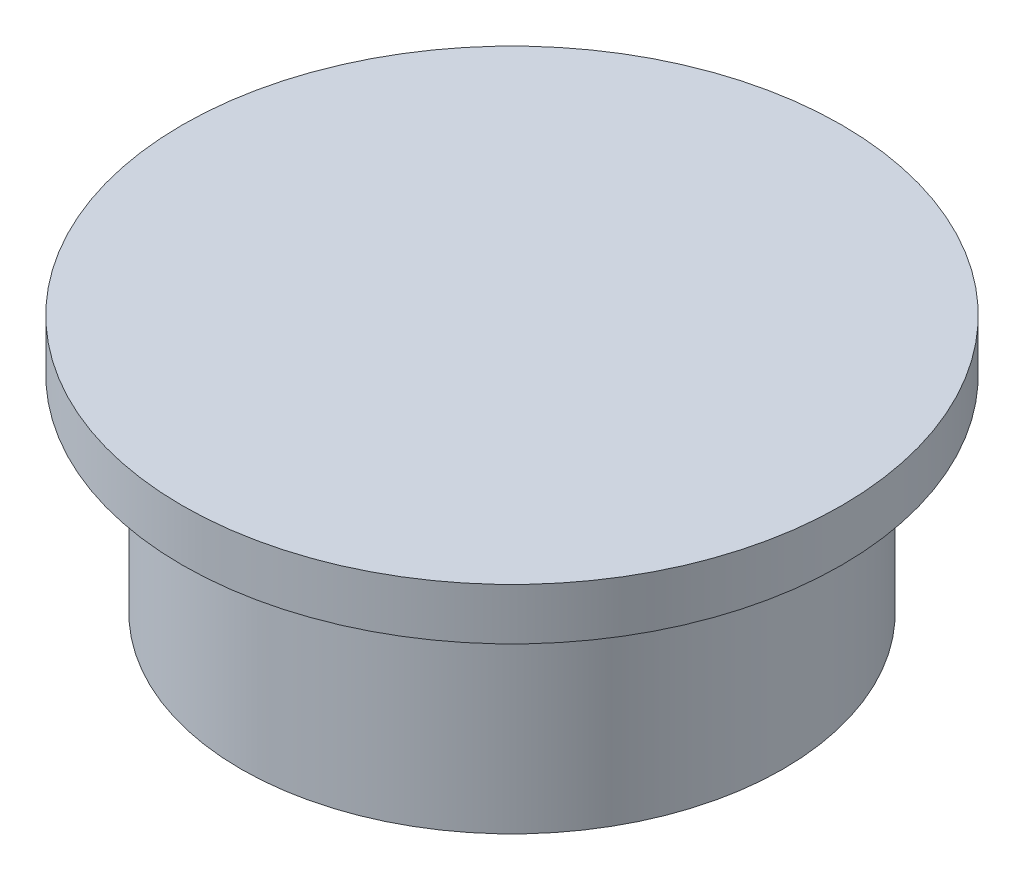
from build123d import *

# Parameters (mm, degrees)
SKETCH1_R           = 12.65
SKETCH1_R_2         = 10.65
BOSS_EXTRUDE1_DEPTH = 15
SKETCH2_R           = 16
BOSS_EXTRUDE2_DEPTH = 2
CUT_EXTRUDE2_DEPTH  = 3.3
SKETCH5_R           = 16
BOSS_EXTRUDE4_DEPTH = 0.5
SKETCH7_R           = 13.15
SKETCH7_R_2         = 12.65
BOSS_EXTRUDE5_DEPTH = 15
BOSS_EXTRUDE6_DEPTH = 2
SKETCH10_R          = 13.15
CUT_EXTRUDE3_DEPTH  = 5
SKETCH11_R          = 10.65
CUT_EXTRUDE4_DEPTH  = 2


with BuildPart() as part:
    # Sketch1 → Boss-Extrude1 (new body)
    with BuildSketch(Plane(origin=(0, 0, 0), x_dir=(1, 0, 0), z_dir=(0, 1, 0))):
        with Locations(Location((0, 0, 0), (0, 0, 270))):
            Circle(SKETCH1_R)
        with Locations(Location((0, 0, 0), (0, 0, 270))):
            Circle(SKETCH1_R_2, mode=Mode.SUBTRACT)
    extrude(amount=BOSS_EXTRUDE1_DEPTH)

    # Sketch2 → Boss-Extrude2 (add)
    with BuildSketch(Plane(origin=(0, 15, 0), x_dir=(1, 0, 0), z_dir=(0, 1, 0))):
        with Locations(Location((0, 0, 0), (0, 0, 270))):
            Circle(SKETCH2_R)
    extrude(amount=BOSS_EXTRUDE2_DEPTH)

    # Sketch4 → Cut-Extrude2 (cut)
    with BuildSketch(Plane(origin=(0, 17, 0), x_dir=(1, 0, 0), z_dir=(0, 1, 0))):
        with BuildLine():
            ThreePointArc((-7.706902754, 1.808391197), (-7.603132783, 1.898306548), (-7.527733553, 2.013058165))
            add(Edge.make_bspline(
                [(-5.973562898, 3.427644412), (-6.705514393, 3.181828062), (-7.188037686, 2.727956598), (-7.527733553, 2.013058165)],
                knots=[0.175947617, 0.175947617, 0.175947617, 0.175947617, 0.967261409, 0.967261409, 0.967261409, 0.967261409], degree=3))
            ThreePointArc((-5.973562898, 3.427644412), (-5.5249107, 3.522844059), (-5.066368092, 3.513333887))
            add(Edge.make_bspline(
                [(0.252246957, 2.546498923), (-0.967265157, 2.585544634), (-2.911735898, 3.219251878), (-5.066368092, 3.513333887)],
                knots=[0, 0, 0, 0, 0.944652434, 0.944652434, 0.944652434, 0.944652434], degree=3))
            add(Edge.make_bspline(
                [(2.984843767, 2.898010668), (1.699544821, 2.557369315), (0.252246957, 2.546498923)],
                knots=[0, 0, 0, 1, 1, 1], degree=2))
            add(Edge.make_bspline(
                [(1.446576088, 1.819612756), (1.692233604, 2.009446504), (2.255675441, 2.356061237), (2.984843767, 2.898010668)],
                knots=[0.144955644, 0.144955644, 0.144955644, 0.144955644, 1, 1, 1, 1], degree=3))
            ThreePointArc((1.446576088, 1.819612756), (1.407722351, 1.740462389), (1.446612546, 1.661329929))
            add(Edge.make_bspline(
                [(10.133171434, -3.748192499), (7.984235622, -2.549090336), (4.381903984, -0.604779848), (1.446612546, 1.661329929)],
                knots=[0.010904337, 0.010904337, 0.010904337, 0.010904337, 1, 1, 1, 1], degree=3))
            Line((10.133171434, -3.748192499), (-3.273421479, -3.865089106))
            add(Edge.make_bspline(
                [(-7.527733553, 0.078549357), (-6.021351328, 0.034537537), (-5.034172952, -1.161131544), (-3.273421479, -3.865089106)],
                knots=[0, 0, 0, 0, 1, 1, 1, 1], degree=3))
            add(Edge.make_bspline(
                [(-9.001359598, -0.096644929), (-8.609511327, -0.010984191), (-8.147442934, 0.043060836), (-7.527733553, 0.078549357)],
                knots=[0.366671919, 0.366671919, 0.366671919, 0.366671919, 1, 1, 1, 1], degree=3))
            ThreePointArc((-9.001359598, -0.096644929), (-9.440291534, -0.378150341), (-9.589622684, -0.877756935))
            Line((-9.589622684, -0.877756935), (-9.555879634, -1.399381307))
            Line((-9.555879634, -1.399381307), (-10.239201334, 0.078549357))
            ThreePointArc((-10.239201334, 0.078549357), (-10.259690649, 0.446534823), (-10.022461777, 0.728590805))
            add(Edge.make_bspline(
                [(-7.706902754, 1.808391197), (-8.132820465, 1.531622413), (-9.295077766, 1.120365549), (-10.022461777, 0.728590805)],
                knots=[0.10934646, 0.10934646, 0.10934646, 0.10934646, 0.840811763, 0.840811763, 0.840811763, 0.840811763], degree=3))
        make_face()
        with BuildLine():
            add(Edge.make_bspline(
                [(-6.583224352, 1.672229032), (-6.265045802, 1.812995825), (-5.554174981, 1.756337096)],
                knots=[0, 0, 0, 1, 1, 1], degree=2))
            ThreePointArc((-5.554174981, 1.756337096), (-5.456989048, 1.782455761), (-5.398182511, 1.864120205))
            add(Edge.make_bspline(
                [(-5.398182511, 1.864120205), (-5.299215588, 2.205704199), (-5.024689184, 2.452345347)],
                knots=[0, 0, 0, 1, 1, 1], degree=2))
            add(Edge.make_bspline(
                [(-5.024689184, 2.452345347), (-5.951430889, 2.228368239), (-6.944366579, 2.126753853)],
                knots=[0, 0, 0, 1, 1, 1], degree=2))
            add(Edge.make_bspline(
                [(-6.944366579, 2.126753853), (-6.855792408, 2.003769494), (-6.788085292, 1.768000929)],
                knots=[0, 0, 0, 1, 1, 1], degree=2))
            ThreePointArc((-6.788085292, 1.768000929), (-6.707437973, 1.673519717), (-6.583224352, 1.672229032))
        make_face(mode=Mode.SUBTRACT)
        with BuildLine():
            ThreePointArc((-6.788085292, 1.768000929), (-6.707437973, 1.673519717), (-6.583224352, 1.672229032))
            add(Edge.make_bspline(
                [(-6.583224352, 1.672229032), (-6.265045802, 1.812995825), (-5.554174981, 1.756337096)],
                knots=[0, 0, 0, 1, 1, 1], degree=2))
            ThreePointArc((-5.554174981, 1.756337096), (-5.456989048, 1.782455761), (-5.398182511, 1.864120205))
            add(Edge.make_bspline(
                [(-5.398182511, 1.864120205), (-5.299215588, 2.205704199), (-5.024689184, 2.452345347)],
                knots=[0, 0, 0, 1, 1, 1], degree=2))
            add(Edge.make_bspline(
                [(-5.024689184, 2.452345347), (-5.951430889, 2.228368239), (-6.944366579, 2.126753853)],
                knots=[0, 0, 0, 1, 1, 1], degree=2))
            add(Edge.make_bspline(
                [(-6.944366579, 2.126753853), (-6.855792408, 2.003769494), (-6.788085292, 1.768000929)],
                knots=[0, 0, 0, 1, 1, 1], degree=2))
        make_face()
    extrude(amount=-CUT_EXTRUDE2_DEPTH, mode=Mode.SUBTRACT)

    # Sketch5 → Boss-Extrude4 (add)
    with BuildSketch(Plane(origin=(0, 17, 0), x_dir=(1, 0, 0), z_dir=(0, 1, 0))):
        with Locations(Location((0, 0, 0), (0, 0, 270))):
            Circle(SKETCH5_R)
    extrude(amount=BOSS_EXTRUDE4_DEPTH)

    # Sketch7 → Boss-Extrude5 (add)
    with BuildSketch(Plane.XZ):
        with Locations(Location((0, 0, 0), (0, 0, 270))):
            Circle(SKETCH7_R)
        Circle(SKETCH7_R_2, mode=Mode.SUBTRACT)
    extrude(amount=-BOSS_EXTRUDE5_DEPTH)

    # Sketch8 → Boss-Extrude6 (add)
    with BuildSketch(Plane.XZ.offset(-15)):
        with BuildLine():
            add(Edge.make_bspline(
                [(9.996866834, 3.672213707), (10.042920822, 3.697861429), (10.088362097, 3.723188972), (10.133171434, 3.748192499)],
                knots=[0.979375502, 0.979375502, 0.979375502, 0.979375502, 1, 1, 1, 1], degree=3))
            Line((10.133171434, 3.748192499), (9.9680871, 3.749631925))
            Line((9.9680871, 3.749631925), (-3.273421479, 3.865089106))
            add(Edge.make_bspline(
                [(-3.273421479, 3.865089106), (-5.034172952, 1.161131544), (-6.021351328, -0.034537537), (-7.527733553, -0.078549357)],
                knots=[0, 0, 0, 0, 1, 1, 1, 1], degree=3))
            add(Edge.make_bspline(
                [(-7.527733553, -0.078549357), (-8.147442934, -0.043060836), (-8.609511327, 0.010984191), (-9.001359598, 0.096644929)],
                knots=[0.366671919, 0.366671919, 0.366671919, 0.366671919, 1, 1, 1, 1], degree=3))
            ThreePointArc((-9.001359598, 0.096644929), (-9.440291534, 0.378150341), (-9.589622684, 0.877756935))
            Line((-9.589622684, 0.877756935), (-9.555879634, 1.399381307))
            Line((-9.555879634, 1.399381307), (-10.239201334, -0.078549357))
            ThreePointArc((-10.239201334, -0.078549357), (-10.259690649, -0.446534823), (-10.022461777, -0.728590805))
            add(Edge.make_bspline(
                [(-10.022461777, -0.728590805), (-9.295077766, -1.120365549), (-8.132820465, -1.531622413), (-7.706902754, -1.808391197)],
                knots=[0.10934646, 0.10934646, 0.10934646, 0.10934646, 0.840811763, 0.840811763, 0.840811763, 0.840811763], degree=3))
            ThreePointArc((-7.706902754, -1.808391197), (-7.603132783, -1.898306548), (-7.527733553, -2.013058165))
            add(Edge.make_bspline(
                [(-7.527733553, -2.013058165), (-7.188037686, -2.727956598), (-6.705514393, -3.181828062), (-5.973562898, -3.427644412)],
                knots=[0.175947617, 0.175947617, 0.175947617, 0.175947617, 0.967261409, 0.967261409, 0.967261409, 0.967261409], degree=3))
            ThreePointArc((-5.973562898, -3.427644412), (-5.5249107, -3.522844059), (-5.066368092, -3.513333887))
            add(Edge.make_bspline(
                [(-5.066368092, -3.513333887), (-2.911735898, -3.219251878), (-0.967265157, -2.585544634), (0.252246944, -2.546498923)],
                knots=[0, 0, 0, 0, 0.944652434, 0.944652434, 0.944652434, 0.944652434], degree=3))
            add(Edge.make_bspline(
                [(0.252246944, -2.546498923), (1.699544832, -2.557369314), (2.984843797, -2.898010676)],
                knots=[0, 0, 0, 1, 1, 1], degree=2))
            add(Edge.make_bspline(
                [(2.984843797, -2.898010676), (2.255675441, -2.356061237), (1.692233604, -2.009446504), (1.446576086, -1.819612759)],
                knots=[0.144955644, 0.144955644, 0.144955644, 0.144955644, 1, 1, 1, 1], degree=3))
            ThreePointArc((1.446576086, -1.819612759), (1.407722347, -1.740462389), (1.446612544, -1.661329926))
            add(Edge.make_bspline(
                [(1.446612544, -1.661329926), (4.320697658, 0.557527214), (7.834294925, 2.467865384), (9.996866834, 3.672213707)],
                knots=[0.010904337, 0.010904337, 0.010904337, 0.010904337, 0.979375502, 0.979375502, 0.979375502, 0.979375502], degree=3))
        make_face()
        with BuildLine():
            Line((-3.273421479, 3.865089106), (9.9680871, 3.749631925))
            ThreePointArc((9.9680871, 3.749631925), (-9.982552018, -3.710950716), (9.996866834, 3.672213707))
            add(Edge.make_bspline(
                [(1.446612544, -1.661329926), (4.320697658, 0.557527214), (7.834294925, 2.467865384), (9.996866834, 3.672213707)],
                knots=[0.010904337, 0.010904337, 0.010904337, 0.010904337, 0.979375502, 0.979375502, 0.979375502, 0.979375502], degree=3))
            ThreePointArc((1.446612544, -1.661329926), (1.407722347, -1.740462389), (1.446576086, -1.819612759))
            add(Edge.make_bspline(
                [(2.984843797, -2.898010676), (2.255675441, -2.356061237), (1.692233604, -2.009446504), (1.446576086, -1.819612759)],
                knots=[0.144955644, 0.144955644, 0.144955644, 0.144955644, 1, 1, 1, 1], degree=3))
            add(Edge.make_bspline(
                [(0.252246944, -2.546498923), (1.699544832, -2.557369314), (2.984843797, -2.898010676)],
                knots=[0, 0, 0, 1, 1, 1], degree=2))
            add(Edge.make_bspline(
                [(-5.066368092, -3.513333887), (-2.911735898, -3.219251878), (-0.967265157, -2.585544634), (0.252246944, -2.546498923)],
                knots=[0, 0, 0, 0, 0.944652434, 0.944652434, 0.944652434, 0.944652434], degree=3))
            ThreePointArc((-5.066368092, -3.513333887), (-5.5249107, -3.522844059), (-5.973562898, -3.427644412))
            add(Edge.make_bspline(
                [(-7.527733553, -2.013058165), (-7.188037686, -2.727956598), (-6.705514393, -3.181828062), (-5.973562898, -3.427644412)],
                knots=[0.175947617, 0.175947617, 0.175947617, 0.175947617, 0.967261409, 0.967261409, 0.967261409, 0.967261409], degree=3))
            ThreePointArc((-7.527733553, -2.013058165), (-7.603132783, -1.898306548), (-7.706902754, -1.808391197))
            add(Edge.make_bspline(
                [(-10.022461777, -0.728590805), (-9.295077766, -1.120365549), (-8.132820465, -1.531622413), (-7.706902754, -1.808391197)],
                knots=[0.10934646, 0.10934646, 0.10934646, 0.10934646, 0.840811763, 0.840811763, 0.840811763, 0.840811763], degree=3))
            ThreePointArc((-10.022461777, -0.728590805), (-10.259690649, -0.446534823), (-10.239201334, -0.078549357))
            Line((-10.239201334, -0.078549357), (-9.555879634, 1.399381307))
            Line((-9.555879634, 1.399381307), (-9.589622684, 0.877756935))
            ThreePointArc((-9.589622684, 0.877756935), (-9.440291534, 0.378150341), (-9.001359598, 0.096644929))
            add(Edge.make_bspline(
                [(-7.527733553, -0.078549357), (-8.147442934, -0.043060836), (-8.609511327, 0.010984191), (-9.001359598, 0.096644929)],
                knots=[0.366671919, 0.366671919, 0.366671919, 0.366671919, 1, 1, 1, 1], degree=3))
            add(Edge.make_bspline(
                [(-3.273421479, 3.865089106), (-5.034172952, 1.161131544), (-6.021351328, -0.034537537), (-7.527733553, -0.078549357)],
                knots=[0, 0, 0, 0, 1, 1, 1, 1], degree=3))
        make_face()
    extrude(amount=BOSS_EXTRUDE6_DEPTH)

    # Sketch10 → Cut-Extrude3 (cut)
    with BuildSketch(Plane.XZ):
        with Locations(Location((0, 0, 0), (0, 0, 270))):
            Circle(SKETCH10_R)
    extrude(amount=-CUT_EXTRUDE3_DEPTH, mode=Mode.SUBTRACT)

    # Sketch11 → Cut-Extrude4 (cut)
    with BuildSketch(Plane.XZ.offset(-13)):
        with Locations(Location((0, 0, 0), (0, 0, 270))):
            Circle(SKETCH11_R)
    extrude(amount=-CUT_EXTRUDE4_DEPTH, mode=Mode.SUBTRACT)


solid = part.part
